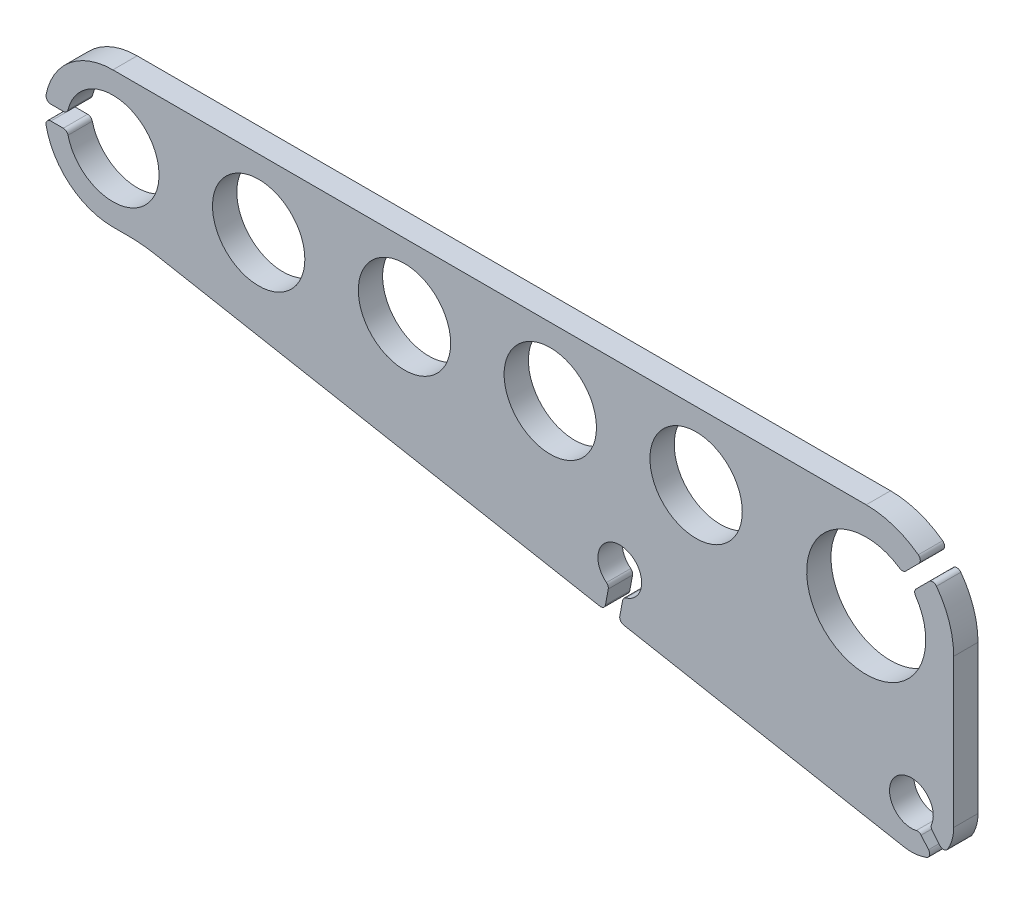
from build123d import *

# Parameters (mm, degrees)
SKETCH1_R      = 9.5
EXTRUDE1_DEPTH = 5


with BuildPart() as part:
    # Sketch1 → Extrude1 (new body)
    with BuildSketch(Plane.XY):
        with BuildLine():
            Line((0, 14), (155, 14))
            ThreePointArc((155, 14), (160.643434486, 13.092444155), (165.717787645, 10.461294133))
            ThreePointArc((165.717787645, 10.461294133), (166.119633231, 9.731618991), (165.829461779, 8.950782122))
            Line((165.829461779, 8.950782122), (163.140222938, 6.261543282))
            ThreePointArc((163.140222938, 6.261543282), (162.527882268, 5.973150498), (161.872126258, 6.140827417))
            ThreePointArc((161.872126258, 6.140827417), (146.33794193, -12.66205807), (165.140827417, 2.872126258))
            ThreePointArc((165.140827417, 2.872126258), (164.973150498, 3.527882268), (165.261543282, 4.140222938))
            Line((165.261543282, 4.140222938), (167.950782122, 6.829461779))
            ThreePointArc((167.950782122, 6.829461779), (168.731618991, 7.119633231), (169.461294133, 6.717787645))
            ThreePointArc((169.461294133, 6.717787645), (172.092444155, 1.643434486), (173, -4))
            Line((173, -4), (173, -34.5))
            ThreePointArc((173, -34.5), (172.682195303, -36.830428123), (171.751990775, -38.990662972))
            ThreePointArc((171.751990775, -38.990662972), (170.973301155, -39.471650118), (170.129341386, -39.117477748))
            Line((170.129341386, -39.117477748), (168.594776555, -37.288654597))
            ThreePointArc((168.594776555, -37.288654597), (168.37185122, -36.79398444), (168.440072921, -36.255709354))
            ThreePointArc((168.440072921, -36.255709354), (161.404162333, -31.052800006), (165.306254745, -38.88529503))
            ThreePointArc((165.306254745, -38.88529503), (165.848198797, -38.911580258), (166.296643225, -39.217017426))
            Line((166.296643225, -39.217017426), (167.831208056, -41.045840577))
            ThreePointArc((167.831208056, -41.045840577), (168.033447677, -41.938480088), (167.424549772, -42.621817122))
            ThreePointArc((167.424549772, -42.621817122), (165.097799098, -43.166346819), (162.710657326, -43.057555971))
            Line((162.710657326, -43.057555971), (105.10076609, -32.38019375))
            ThreePointArc((105.10076609, -32.38019375), (104.458875427, -31.96334508), (104.299746708, -31.214703317))
            Line((104.299746708, -31.214703317), (104.878820837, -28.090298909))
            ThreePointArc((104.878820837, -28.090298909), (105.118722541, -27.603635328), (105.577463168, -27.31389181))
            ThreePointArc((105.577463168, -27.31389181), (105.116766441, -18.575352916), (101.555056728, -26.568382843))
            ThreePointArc((101.555056728, -26.568382843), (101.879493209, -27.003279657), (101.929056114, -27.543592333))
            Line((101.929056114, -27.543592333), (101.349981985, -30.667996741))
            ThreePointArc((101.349981985, -30.667996741), (100.933133315, -31.309887404), (100.184491552, -31.469016123))
            Line((100.184491552, -31.469016123), (8.640568057, -14.502352773))
            ThreePointArc((8.640568057, -14.502352773), (5.918550852, -14.125852173), (3.173502293, -14))
            Line((3.173502293, -14), (0, -14))
            ThreePointArc((0, -14), (-8.89684473, -10.809539946), (-13.738685501, -2.692307692))
            ThreePointArc((-13.738685501, -2.692307692), (-13.529460818, -1.864511091), (-12.757350822, -1.5))
            Line((-12.757350822, -1.5), (-10.198039027, -1.5))
            ThreePointArc((-10.198039027, -1.5), (-9.580825627, -1.713204208), (-9.226797215, -2.261904762))
            ThreePointArc((-9.226797215, -2.261904762), (9.5, 0), (-9.226797215, 2.261904762))
            ThreePointArc((-9.226797215, 2.261904762), (-9.580825627, 1.713204208), (-10.198039027, 1.5))
            Line((-10.198039027, 1.5), (-12.757350822, 1.5))
            ThreePointArc((-12.757350822, 1.5), (-13.529460818, 1.864511091), (-13.738685501, 2.692307692))
            ThreePointArc((-13.738685501, 2.692307692), (-8.89684473, 10.809539946), (0, 14))
        make_face()
        with Locations((30, 0)):
            Circle(SKETCH1_R, mode=Mode.SUBTRACT)
        with Locations((60, 0)):
            Circle(SKETCH1_R, mode=Mode.SUBTRACT)
        with Locations((90, 0)):
            Circle(SKETCH1_R, mode=Mode.SUBTRACT)
        with Locations((120, 0)):
            Circle(SKETCH1_R, mode=Mode.SUBTRACT)
    extrude(amount=EXTRUDE1_DEPTH)


solid = part.part
